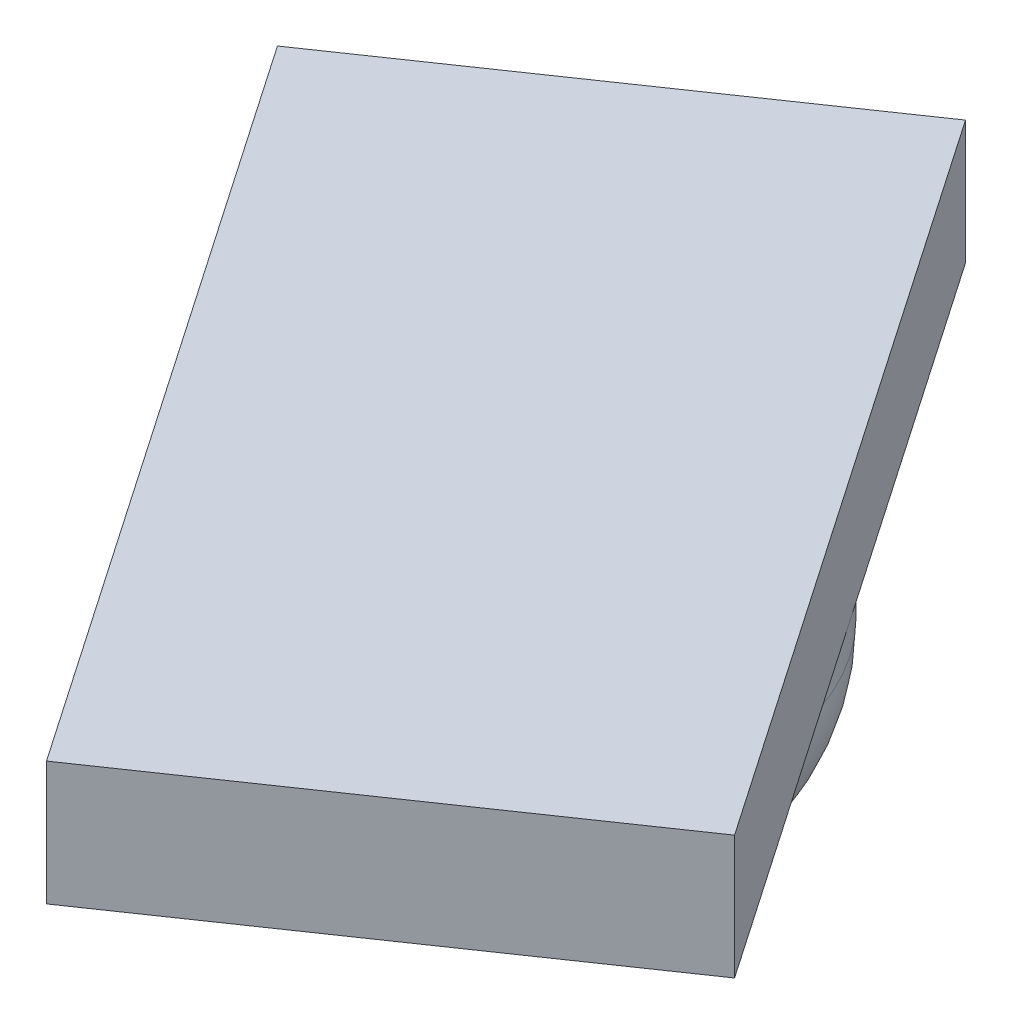
from build123d import *

# Parameters (mm, degrees)
SKETCH1_R           = 4
BOSS_EXTRUDE1_DEPTH = 5.5
BOSS_EXTRUDE2_DEPTH = 2
FILLET3_R           = 3


with BuildPart() as part:
    # Sketch1 → Boss-Extrude1 (new body)
    with BuildSketch(Plane(origin=(0, 0, 0), x_dir=(1, 0, 0), z_dir=(0, 1, 0))):
        Circle(SKETCH1_R)
    extrude(amount=BOSS_EXTRUDE1_DEPTH)

    # Sketch2 → Boss-Extrude2 (add)
    with BuildSketch(Plane(origin=(0, 5.5, 0), x_dir=(1, 0, 0), z_dir=(0, 1, 0))):
        Polygon((0.772583445, -8.200189926), (7.3705827, -3.676208734), (-0.772583445, 8.200189926), (-7.3705827, 3.676208734), align=None)
    extrude(amount=-BOSS_EXTRUDE2_DEPTH)

    # Fillet3
    fillet3_edges = [part.edges().sort_by_distance(p)[0] for p in [
        (-4, 0, 0),
    ]]
    fillet(fillet3_edges, radius=FILLET3_R)


solid = part.part
